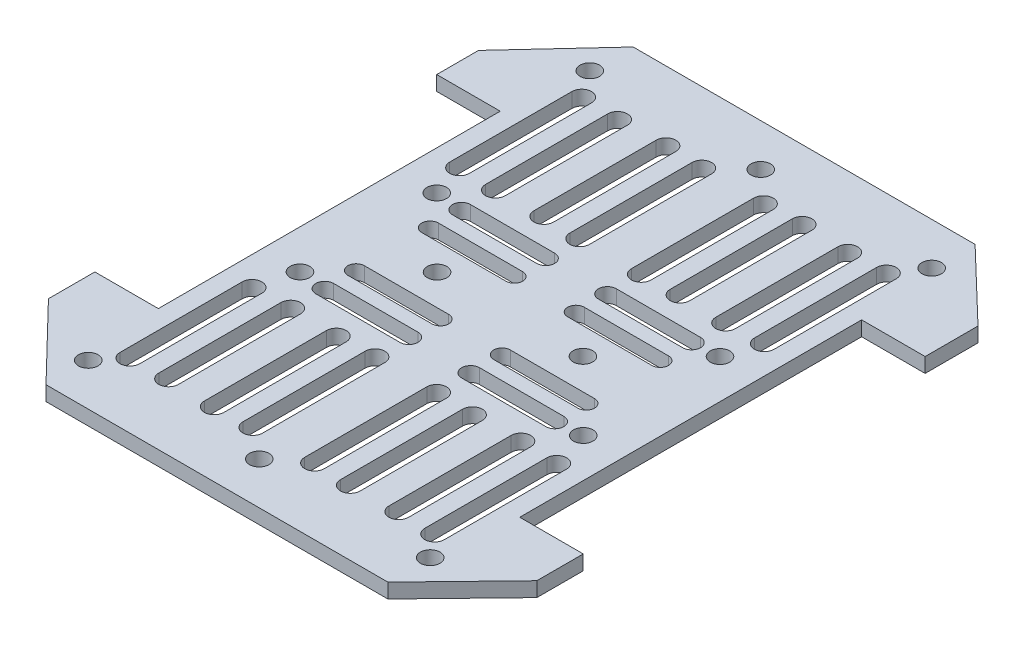
from build123d import *

# Parameters (mm, degrees)
SKETCH1_R           = 2
BOSS_EXTRUDE1_DEPTH = 3


with BuildPart() as part:
    # Sketch1 → Boss-Extrude1 (new body)
    with BuildSketch(Plane(origin=(0, 0, 0), x_dir=(1, 0, 0), z_dir=(0, 1, 0))):
        Polygon((-117.708234781, 46.18565323), (-117.708234781, 37.539058804), (-104.708234781, 37.539058804), (-104.708234781, -32.460941196), (-117.708234781, -32.460941196), (-117.708234781, -41.961747622), (-102.708234781, -57.460941196), (-32.708234781, -57.460941196), (-17.708234781, -41.961747622), (-17.708234781, -32.460941196), (-30.708234781, -32.460941196), (-30.708234781, 37.539058804), (-17.708234781, 37.539058804), (-17.708234781, 48.362937983), (-32.482765457, 62.539058804), (-102.482765457, 62.539058804), (-117.673238758, 46.131294908), align=None)
        with Locations((-96.708234781, 16.539058804)):
            Circle(SKETCH1_R, mode=Mode.SUBTRACT)
        with Locations((-96.708234781, -11.460941196)):
            Circle(SKETCH1_R, mode=Mode.SUBTRACT)
        with Locations((-102.708234781, -48.800687158)):
            Circle(SKETCH1_R, mode=Mode.SUBTRACT)
        with Locations((-67.708234781, -48.800687158)):
            Circle(SKETCH1_R, mode=Mode.SUBTRACT)
        with Locations((-102.708234781, 53.878804766)):
            Circle(SKETCH1_R, mode=Mode.SUBTRACT)
        with Locations((-67.708234781, 53.878804766)):
            Circle(SKETCH1_R, mode=Mode.SUBTRACT)
        with Locations((-32.708234781, 53.878804766)):
            Circle(SKETCH1_R, mode=Mode.SUBTRACT)
        with Locations((-32.708234781, -48.800687158)):
            Circle(SKETCH1_R, mode=Mode.SUBTRACT)
        with Locations((-38.708234781, -11.460941196)):
            Circle(SKETCH1_R, mode=Mode.SUBTRACT)
        with Locations((-38.708234781, 16.539058804)):
            Circle(SKETCH1_R, mode=Mode.SUBTRACT)
        with Locations((-52.771353365, 2.539058804)):
            Circle(SKETCH1_R, mode=Mode.SUBTRACT)
        with Locations((-82.645116197, 2.539058804)):
            Circle(SKETCH1_R, mode=Mode.SUBTRACT)
        with BuildLine():
            Line((-79.583025643, 48.362937983), (-79.583025643, 23.355939616))
            ThreePointArc((-79.583025643, 23.355939616), (-81.595082983, 21.343882276), (-83.607140323, 23.355939616))
            Line((-83.607140323, 23.355939616), (-83.607140323, 48.362937983))
            ThreePointArc((-83.607140323, 48.362937983), (-81.595082983, 50.374995323), (-79.583025643, 48.362937983))
        make_face(mode=Mode.SUBTRACT)
        with BuildLine():
            Line((-71.954133984, 48.07550122), (-71.954133984, 23.068502853))
            ThreePointArc((-71.954133984, 23.068502853), (-73.966191324, 21.056445514), (-75.978248664, 23.068502853))
            Line((-75.978248664, 23.068502853), (-75.978248664, 48.07550122))
            ThreePointArc((-75.978248664, 48.07550122), (-73.966191324, 50.08755856), (-71.954133984, 48.07550122))
        make_face(mode=Mode.SUBTRACT)
        with BuildLine():
            Line((-73.966191324, 14.281397024), (-91.218060864, 14.281397024))
            ThreePointArc((-91.218060864, 14.281397024), (-93.048616644, 16.111952804), (-91.218060864, 17.942508584))
            Line((-91.218060864, 17.942508584), (-73.966191324, 17.942508584))
            ThreePointArc((-73.966191324, 17.942508584), (-72.135635543, 16.111952804), (-73.966191324, 14.281397024))
        make_face(mode=Mode.SUBTRACT)
        with BuildLine():
            Line((-96.834895183, 48.362937983), (-96.834895183, 23.355939616))
            ThreePointArc((-96.834895183, 23.355939616), (-98.846952522, 21.343882276), (-100.859009862, 23.355939616))
            Line((-100.859009862, 23.355939616), (-100.859009862, 48.362937983))
            ThreePointArc((-100.859009862, 48.362937983), (-98.846952522, 50.374995323), (-96.834895183, 48.362937983))
        make_face(mode=Mode.SUBTRACT)
        with BuildLine():
            Line((-89.206003524, 48.07550122), (-89.206003524, 23.068502853))
            ThreePointArc((-89.206003524, 23.068502853), (-91.218060864, 21.056445514), (-93.230118203, 23.068502853))
            Line((-93.230118203, 23.068502853), (-93.230118203, 48.07550122))
            ThreePointArc((-93.230118203, 48.07550122), (-91.218060864, 50.08755856), (-89.206003524, 48.07550122))
        make_face(mode=Mode.SUBTRACT)
        with BuildLine():
            Line((-55.727463713, 48.362937983), (-55.727463713, 23.355939616))
            ThreePointArc((-55.727463713, 23.355939616), (-53.715406373, 21.343882276), (-51.703349033, 23.355939616))
            Line((-51.703349033, 23.355939616), (-51.703349033, 48.362937983))
            ThreePointArc((-51.703349033, 48.362937983), (-53.715406373, 50.374995323), (-55.727463713, 48.362937983))
        make_face(mode=Mode.SUBTRACT)
        with BuildLine():
            Line((-63.356355372, 48.07550122), (-63.356355372, 23.068502853))
            ThreePointArc((-63.356355372, 23.068502853), (-61.344298032, 21.056445514), (-59.332240692, 23.068502853))
            Line((-59.332240692, 23.068502853), (-59.332240692, 48.07550122))
            ThreePointArc((-59.332240692, 48.07550122), (-61.344298032, 50.08755856), (-63.356355372, 48.07550122))
        make_face(mode=Mode.SUBTRACT)
        with BuildLine():
            Line((-38.475594173, 48.362937983), (-38.475594173, 23.355939616))
            ThreePointArc((-38.475594173, 23.355939616), (-36.463536833, 21.343882276), (-34.451479493, 23.355939616))
            Line((-34.451479493, 23.355939616), (-34.451479493, 48.362937983))
            ThreePointArc((-34.451479493, 48.362937983), (-36.463536833, 50.374995323), (-38.475594173, 48.362937983))
        make_face(mode=Mode.SUBTRACT)
        with BuildLine():
            Line((-46.104485832, 48.07550122), (-46.104485832, 23.068502853))
            ThreePointArc((-46.104485832, 23.068502853), (-44.092428492, 21.056445514), (-42.080371152, 23.068502853))
            Line((-42.080371152, 23.068502853), (-42.080371152, 48.07550122))
            ThreePointArc((-42.080371152, 48.07550122), (-44.092428492, 50.08755856), (-46.104485832, 48.07550122))
        make_face(mode=Mode.SUBTRACT)
        with BuildLine():
            Line((-79.583025643, -44.139032376), (-79.583025643, -19.132034009))
            ThreePointArc((-79.583025643, -19.132034009), (-81.595082983, -17.119976669), (-83.607140323, -19.132034009))
            Line((-83.607140323, -19.132034009), (-83.607140323, -44.139032376))
            ThreePointArc((-83.607140323, -44.139032376), (-81.595082983, -46.151089715), (-79.583025643, -44.139032376))
        make_face(mode=Mode.SUBTRACT)
        with BuildLine():
            Line((-71.954133984, -43.851595613), (-71.954133984, -18.844597246))
            ThreePointArc((-71.954133984, -18.844597246), (-73.966191324, -16.832539906), (-75.978248664, -18.844597246))
            Line((-75.978248664, -18.844597246), (-75.978248664, -43.851595613))
            ThreePointArc((-75.978248664, -43.851595613), (-73.966191324, -45.863652953), (-71.954133984, -43.851595613))
        make_face(mode=Mode.SUBTRACT)
        with BuildLine():
            Line((-96.834895183, -44.139032376), (-96.834895183, -19.132034009))
            ThreePointArc((-96.834895183, -19.132034009), (-98.846952522, -17.119976669), (-100.859009862, -19.132034009))
            Line((-100.859009862, -19.132034009), (-100.859009862, -44.139032376))
            ThreePointArc((-100.859009862, -44.139032376), (-98.846952522, -46.151089715), (-96.834895183, -44.139032376))
        make_face(mode=Mode.SUBTRACT)
        with BuildLine():
            Line((-89.206003524, -43.851595613), (-89.206003524, -18.844597246))
            ThreePointArc((-89.206003524, -18.844597246), (-91.218060864, -16.832539906), (-93.230118203, -18.844597246))
            Line((-93.230118203, -18.844597246), (-93.230118203, -43.851595613))
            ThreePointArc((-93.230118203, -43.851595613), (-91.218060864, -45.863652953), (-89.206003524, -43.851595613))
        make_face(mode=Mode.SUBTRACT)
        with BuildLine():
            Line((-55.727463713, -44.139032376), (-55.727463713, -19.132034009))
            ThreePointArc((-55.727463713, -19.132034009), (-53.715406373, -17.119976669), (-51.703349033, -19.132034009))
            Line((-51.703349033, -19.132034009), (-51.703349033, -44.139032376))
            ThreePointArc((-51.703349033, -44.139032376), (-53.715406373, -46.151089715), (-55.727463713, -44.139032376))
        make_face(mode=Mode.SUBTRACT)
        with BuildLine():
            Line((-63.356355372, -43.851595613), (-63.356355372, -18.844597246))
            ThreePointArc((-63.356355372, -18.844597246), (-61.344298032, -16.832539906), (-59.332240692, -18.844597246))
            Line((-59.332240692, -18.844597246), (-59.332240692, -43.851595613))
            ThreePointArc((-59.332240692, -43.851595613), (-61.344298032, -45.863652953), (-63.356355372, -43.851595613))
        make_face(mode=Mode.SUBTRACT)
        with BuildLine():
            Line((-38.475594173, -44.139032376), (-38.475594173, -19.132034009))
            ThreePointArc((-38.475594173, -19.132034009), (-36.463536833, -17.119976669), (-34.451479493, -19.132034009))
            Line((-34.451479493, -19.132034009), (-34.451479493, -44.139032376))
            ThreePointArc((-34.451479493, -44.139032376), (-36.463536833, -46.151089715), (-38.475594173, -44.139032376))
        make_face(mode=Mode.SUBTRACT)
        with BuildLine():
            Line((-46.104485832, -43.851595613), (-46.104485832, -18.844597246))
            ThreePointArc((-46.104485832, -18.844597246), (-44.092428492, -16.832539906), (-42.080371152, -18.844597246))
            Line((-42.080371152, -18.844597246), (-42.080371152, -43.851595613))
            ThreePointArc((-42.080371152, -43.851595613), (-44.092428492, -45.863652953), (-46.104485832, -43.851595613))
        make_face(mode=Mode.SUBTRACT)
        with BuildLine():
            Line((-73.966191324, 7.984384289), (-91.218060864, 7.984384289))
            ThreePointArc((-91.218060864, 7.984384289), (-92.918765354, 9.685088779), (-91.218060864, 11.385793269))
            Line((-91.218060864, 11.385793269), (-73.966191324, 11.385793269))
            ThreePointArc((-73.966191324, 11.385793269), (-72.265486834, 9.685088779), (-73.966191324, 7.984384289))
        make_face(mode=Mode.SUBTRACT)
        with BuildLine():
            Line((-61.344298032, 14.281397024), (-44.092428492, 14.281397024))
            ThreePointArc((-44.092428492, 14.281397024), (-42.261872712, 16.111952804), (-44.092428492, 17.942508584))
            Line((-44.092428492, 17.942508584), (-61.344298032, 17.942508584))
            ThreePointArc((-61.344298032, 17.942508584), (-63.174853812, 16.111952804), (-61.344298032, 14.281397024))
        make_face(mode=Mode.SUBTRACT)
        with BuildLine():
            Line((-61.344298032, 7.984384289), (-44.092428492, 7.984384289))
            ThreePointArc((-44.092428492, 7.984384289), (-42.391724002, 9.685088779), (-44.092428492, 11.385793269))
            Line((-44.092428492, 11.385793269), (-61.344298032, 11.385793269))
            ThreePointArc((-61.344298032, 11.385793269), (-63.045002522, 9.685088779), (-61.344298032, 7.984384289))
        make_face(mode=Mode.SUBTRACT)
        with BuildLine():
            Line((-73.966191324, -10.057491416), (-91.218060864, -10.057491416))
            ThreePointArc((-91.218060864, -10.057491416), (-93.048616644, -11.888047196), (-91.218060864, -13.718602976))
            Line((-91.218060864, -13.718602976), (-73.966191324, -13.718602976))
            ThreePointArc((-73.966191324, -13.718602976), (-72.135635543, -11.888047196), (-73.966191324, -10.057491416))
        make_face(mode=Mode.SUBTRACT)
        with BuildLine():
            Line((-73.966191324, -3.760478681), (-91.218060864, -3.760478681))
            ThreePointArc((-91.218060864, -3.760478681), (-92.918765354, -5.461183171), (-91.218060864, -7.161887662))
            Line((-91.218060864, -7.161887662), (-73.966191324, -7.161887662))
            ThreePointArc((-73.966191324, -7.161887662), (-72.265486834, -5.461183171), (-73.966191324, -3.760478681))
        make_face(mode=Mode.SUBTRACT)
        with BuildLine():
            Line((-61.344298032, -10.057491416), (-44.092428492, -10.057491416))
            ThreePointArc((-44.092428492, -10.057491416), (-42.261872712, -11.888047196), (-44.092428492, -13.718602976))
            Line((-44.092428492, -13.718602976), (-61.344298032, -13.718602976))
            ThreePointArc((-61.344298032, -13.718602976), (-63.174853812, -11.888047196), (-61.344298032, -10.057491416))
        make_face(mode=Mode.SUBTRACT)
        with BuildLine():
            Line((-61.344298032, -3.760478681), (-44.092428492, -3.760478681))
            ThreePointArc((-44.092428492, -3.760478681), (-42.391724002, -5.461183171), (-44.092428492, -7.161887662))
            Line((-44.092428492, -7.161887662), (-61.344298032, -7.161887662))
            ThreePointArc((-61.344298032, -7.161887662), (-63.045002522, -5.461183171), (-61.344298032, -3.760478681))
        make_face(mode=Mode.SUBTRACT)
    extrude(amount=BOSS_EXTRUDE1_DEPTH)


solid = part.part
